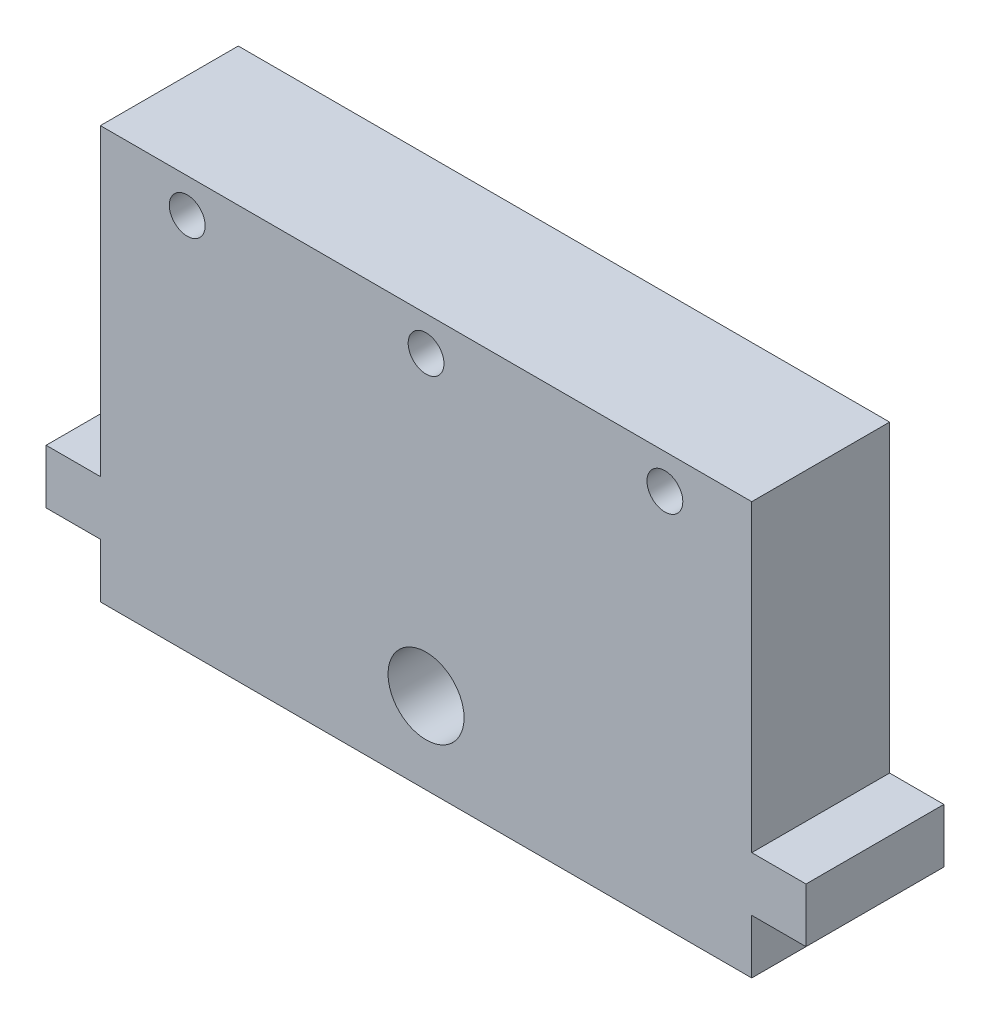
from build123d import *

# Parameters (mm, degrees)
SKETCH1_W                 = 60
SKETCH1_H                 = 12.7
BOSS_EXTRUDE1_DEPTH       = 38
M8X1_0_TAPPED_HOLE1_D     = 7
M8X1_0_TAPPED_HOLE1_DEPTH = 19.05
M8X1_0_TAPPED_HOLE1_TIP   = 2.103012167
BOSS_EXTRUDE3_DEPTH       = 12.7
M4X0_7_TAPPED_HOLE1_D     = 3.3


with BuildPart() as part:
    # Sketch1 → Boss-Extrude1 (new body)
    with BuildSketch(Plane(origin=(0, 0, 0), x_dir=(1, 0, 0), z_dir=(0, 1, 0))):
        with Locations((-30, 6.35)):
            Rectangle(SKETCH1_W, SKETCH1_H)
    extrude(amount=BOSS_EXTRUDE1_DEPTH)

    # M8x1.0 Tapped Hole1
    with Locations(Plane(origin=(-30, 7.5, 0), x_dir=(1, 0, 0), z_dir=(0, 0, 1))):
        with Locations((0, 0)):
            Hole(M8X1_0_TAPPED_HOLE1_D / 2, depth=M8X1_0_TAPPED_HOLE1_DEPTH)
            with Locations((0, 0, -(M8X1_0_TAPPED_HOLE1_DEPTH + M8X1_0_TAPPED_HOLE1_TIP / 2))):  # 118° drill point
                Cone(0, M8X1_0_TAPPED_HOLE1_D / 2, M8X1_0_TAPPED_HOLE1_TIP, mode=Mode.SUBTRACT)

    # Sketch7 → Boss-Extrude3 (add)
    with BuildSketch(Plane.XY):
        Polygon((-60, 7.5), (-60, 10), (-65, 10), (-65, 5), (-60, 5), align=None)
        Polygon((5, 5), (0, 5), (0, 7.5), (0, 10), (5, 10), align=None)
    extrude(amount=-BOSS_EXTRUDE3_DEPTH)

    # M4x0.7 Tapped Hole1 (through all)
    with Locations(Plane(origin=(-52, 34.825, 0), x_dir=(1, 0, 0), z_dir=(0, 0, 1))):
        with Locations((0, 0), (22, 0), (44, 0)):
            Hole(M4X0_7_TAPPED_HOLE1_D / 2)


solid = part.part
